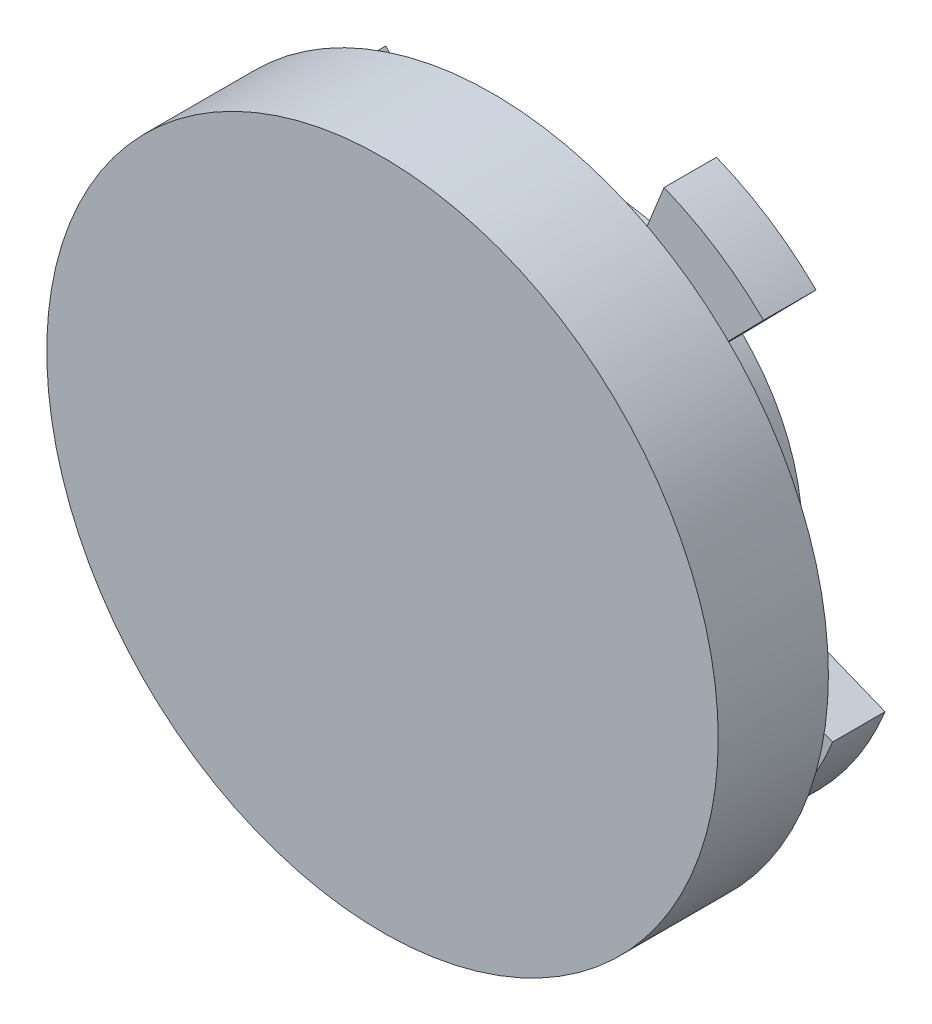
from build123d import *

# Parameters (mm, degrees)
BOSS_EXTRUDE1_DEPTH      = 2.5
SKETCH2_R                = 9.5
BOSS_EXTRUDE2_DEPTH      = 3
SKETCH3_R                = 16
BOSS_EXTRUDE3_DEPTH      = 5
BOSS_EXTRUDE3_DEPTH_BACK = 0.25


with BuildPart() as part:
    # Sketch1 → Boss-Extrude1 (new body)
    with BuildSketch(Plane.XY):
        with BuildLine():
            Line((5.417779502, 13.449820269), (3.549579674, 8.811951211))
            ThreePointArc((3.549579674, 8.811951211), (-1.94104371, 9.299588664), (-6.778170146, 6.656305993))
            Line((-6.778170146, 6.656305993), (-10.345628118, 10.159624937))
            ThreePointArc((-10.345628118, 10.159624937), (-12.131657575, 7.941843897), (-13.449820269, 5.417779502))
            Line((-13.449820269, 5.417779502), (-8.811951211, 3.549579674))
            ThreePointArc((-8.811951211, 3.549579674), (-9.299588664, -1.94104371), (-6.656305993, -6.778170146))
            Line((-6.656305993, -6.778170146), (-10.159624937, -10.345628118))
            ThreePointArc((-10.159624937, -10.345628118), (-7.941843897, -12.131657575), (-5.417779502, -13.449820269))
            Line((-5.417779502, -13.449820269), (-3.549579674, -8.811951211))
            ThreePointArc((-3.549579674, -8.811951211), (1.94104371, -9.299588664), (6.778170146, -6.656305993))
            Line((6.778170146, -6.656305993), (10.345628118, -10.159624937))
            ThreePointArc((10.345628118, -10.159624937), (12.131657575, -7.941843897), (13.449820269, -5.417779502))
            Line((13.449820269, -5.417779502), (8.811951211, -3.549579674))
            ThreePointArc((8.811951211, -3.549579674), (9.299588664, 1.94104371), (6.656305993, 6.778170146))
            Line((6.656305993, 6.778170146), (10.159624937, 10.345628118))
            ThreePointArc((10.159624937, 10.345628118), (7.941843897, 12.131657575), (5.417779502, 13.449820269))
        make_face()
    extrude(amount=BOSS_EXTRUDE1_DEPTH)

    # Sketch2 → Boss-Extrude2 (add)
    with BuildSketch(Plane.XY.offset(2.5)):
        Circle(SKETCH2_R)
    extrude(amount=BOSS_EXTRUDE2_DEPTH)

    # Sketch3 → Boss-Extrude3 (add, two sides)
    with BuildSketch(Plane.XY.offset(5.5)) as boss_extrude3_sk:
        Circle(SKETCH3_R)
    extrude(amount=BOSS_EXTRUDE3_DEPTH)
    extrude(boss_extrude3_sk.sketch, amount=-BOSS_EXTRUDE3_DEPTH_BACK)


solid = part.part
